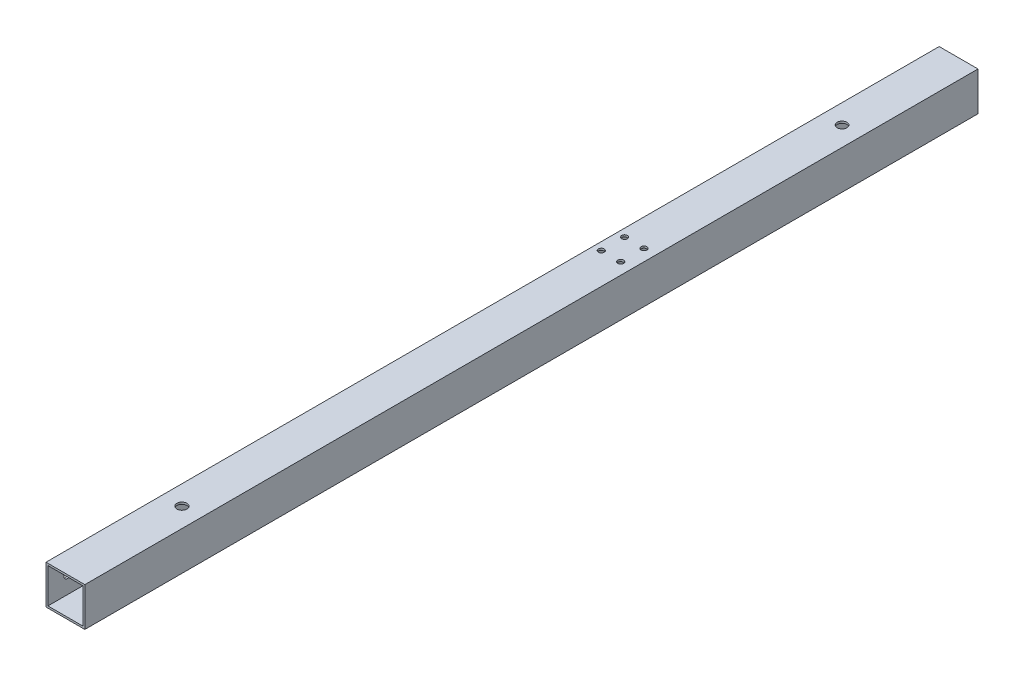
from build123d import *

# Parameters (mm, degrees)
SKETCH_1_W          = 20
SKETCH_1_H          = 20
SKETCH_1_W_2        = 18
SKETCH_1_H_2        = 18
EXTRUDE_1_DEPTH     = 460
SKETCH_2_R          = 1.8
CUT_EXTRUDE_1_DEPTH = 3
SKETCH_3_R          = 1.8
CUT_EXTRUDE_2_DEPTH = 3
SKETCH_5_R          = 1.8
CUT_EXTRUDE_3_DEPTH = 3
SKETCH_6_R          = 1.8
CUT_EXTRUDE_4_DEPTH = 10
SKETCH_7_R          = 1.5
CUT_EXTRUDE_5_DEPTH = 20
SKETCH1_R           = 2.5
CUT_EXTRUDE1_DEPTH  = 20
SKETCH2_R           = 2.6
CUT_EXTRUDE2_DEPTH  = 36


with BuildPart() as part:
    # 草图1 → 凸台-拉伸1 (new body)
    with BuildSketch(Plane.XY):
        Rectangle(SKETCH_1_W, SKETCH_1_H)
        Rectangle(SKETCH_1_W_2, SKETCH_1_H_2, mode=Mode.SUBTRACT)
    extrude(amount=EXTRUDE_1_DEPTH)

    # 草图2 → 切除-拉伸1 (cut)
    with BuildSketch(Plane.ZY.offset(10)):
        with Locations((10, 0)):
            Circle(SKETCH_2_R)
    extrude(amount=-CUT_EXTRUDE_1_DEPTH, mode=Mode.SUBTRACT)

    # 草图3 → 切除-拉伸2 (cut)
    with BuildSketch(Plane.ZY.offset(10)):
        with Locations((198, 0)):
            Circle(SKETCH_3_R)
    extrude(amount=-CUT_EXTRUDE_2_DEPTH, mode=Mode.SUBTRACT)

    # 草图5 → 切除-拉伸3 (cut)
    with BuildSketch(Plane.ZY.offset(10)):
        with Locations((450, 0)):
            Circle(SKETCH_5_R)
    extrude(amount=-CUT_EXTRUDE_3_DEPTH, mode=Mode.SUBTRACT)

    # 草图6 → 切除-拉伸4 (cut)
    with BuildSketch(Plane.ZY.offset(10)):
        with Locations((262, 0)):
            Circle(SKETCH_6_R)
    extrude(amount=-CUT_EXTRUDE_4_DEPTH, mode=Mode.SUBTRACT)

    # 草图7 → 切除-拉伸5 (cut)
    with BuildSketch(Plane(origin=(0, 10, 0), x_dir=(1, 0, 0), z_dir=(0, 1, 0))):
        with Locations((4, -166)):
            Circle(SKETCH_7_R)
        with Locations((-6, -166)):
            Circle(SKETCH_7_R)
        with Locations((4, -178)):
            Circle(SKETCH_7_R)
        with Locations((-6, -178)):
            Circle(SKETCH_7_R)
    extrude(amount=-CUT_EXTRUDE_5_DEPTH, mode=Mode.SUBTRACT)

    # Sketch1 → Cut-Extrude1 (cut)
    with BuildSketch(Plane.XZ.offset(10)):
        with Locations((0, 60)):
            Circle(SKETCH1_R)
    extrude(amount=-CUT_EXTRUDE1_DEPTH, mode=Mode.SUBTRACT)

    # Sketch2 → Cut-Extrude2 (cut)
    with BuildSketch(Plane.XZ.offset(10)):
        with Locations((0, 400)):
            Circle(SKETCH2_R)
    extrude(amount=-CUT_EXTRUDE2_DEPTH, mode=Mode.SUBTRACT)


solid = part.part
